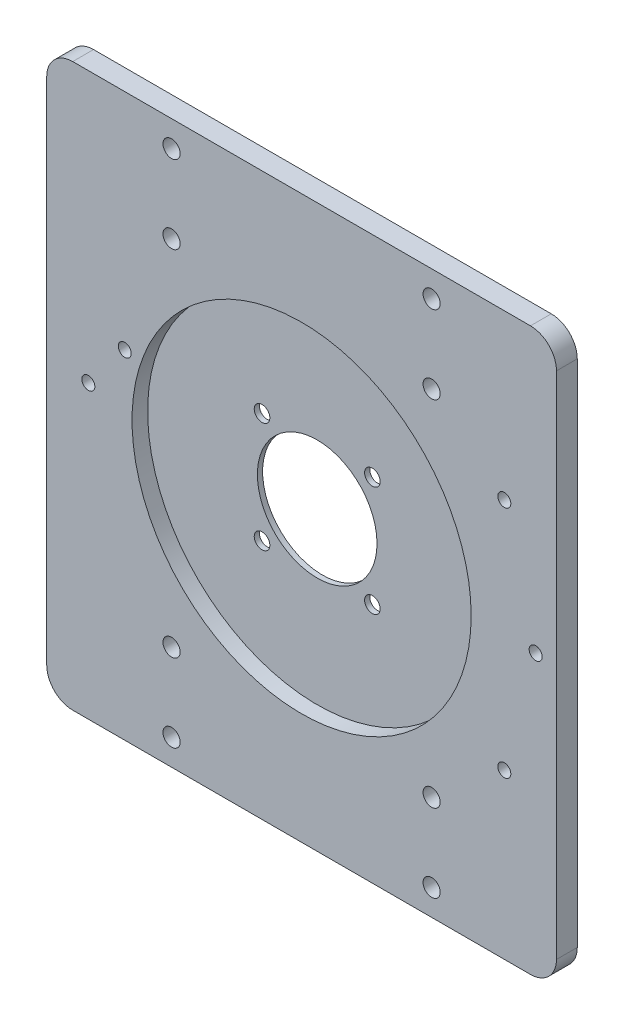
from build123d import *

# Parameters (mm, degrees)
SKETCH_1_W             = 98
SKETCH_1_H             = 108
EXTRUDE_1_DEPTH        = 4
SKETCH_2_R             = 11.5
CUT_EXTRUDE_1_DEPTH    = 10
SKETCH_3_R             = 32.6
CUT_EXTRUDE_2_DEPTH    = 3
SKETCH_4_R             = 1.5
CUT_EXTRUDE_3_DEPTH    = 2
FILLET_1_R             = 5
HOLE_WIZARD_M4_1_D     = 3.3
HOLE_WIZARD_M4_1_DEPTH = 10.1
HOLE_WIZARD_M4_1_TIP   = 0.991420021
HOLE_WIZARD_M3_1_D     = 2.5
HOLE_WIZARD_M3_1_DEPTH = 7.5
HOLE_WIZARD_M3_1_TIP   = 0.751075774
HOLE_WIZARD_M3_2_D     = 2.5
HOLE_WIZARD_M3_2_DEPTH = 7.5
HOLE_WIZARD_M3_2_TIP   = 0.751075774


with BuildPart() as part:
    # 草图1 → 凸台-拉伸1 (new body)
    with BuildSketch(Plane.XY):
        Rectangle(SKETCH_1_W, SKETCH_1_H)
    extrude(amount=EXTRUDE_1_DEPTH)

    # 草图2 → 切除-拉伸1 (cut)
    with BuildSketch(Plane.XY.offset(4)):
        Circle(SKETCH_2_R)
    extrude(amount=-CUT_EXTRUDE_1_DEPTH, mode=Mode.SUBTRACT)

    # 草图3 → 切除-拉伸2 (cut)
    with BuildSketch(Plane.XY.offset(4)):
        Circle(SKETCH_3_R)
    extrude(amount=-CUT_EXTRUDE_2_DEPTH, mode=Mode.SUBTRACT)

    # 草图4 → 切除-拉伸3 (cut)
    with BuildSketch(Plane.XY.offset(1)):
        with Locations((-10.606601718, 10.606601718)):
            Circle(SKETCH_4_R)
        with Locations((10.606601718, -10.606601718)):
            Circle(SKETCH_4_R)
        with Locations((10.606601718, 10.606601718)):
            Circle(SKETCH_4_R)
        with Locations((-10.606601718, -10.606601718)):
            Circle(SKETCH_4_R)
    extrude(amount=-CUT_EXTRUDE_3_DEPTH, mode=Mode.SUBTRACT)

    # 圆角1
    fillet_1_edges = [part.edges().sort_by_distance(p)[0] for p in [
        (-49, 54, 2),
        (49, 54, 2),
        (49, -54, 2),
        (-49, -54, 2),
    ]]
    fillet(fillet_1_edges, radius=FILLET_1_R)

    # M4 螺纹孔1
    with Locations(Plane(origin=(0, 0, 0), x_dir=(-1, 0, 0), z_dir=(0, 0, -1))):
        with Locations((-25, 49), (-25, 34), (25, 34), (25, 49), (-25, -34), (-25, -49), (25, -49), (25, -34)):
            Hole(HOLE_WIZARD_M4_1_D / 2, depth=HOLE_WIZARD_M4_1_DEPTH)
            with Locations((0, 0, -(HOLE_WIZARD_M4_1_DEPTH + HOLE_WIZARD_M4_1_TIP / 2))):  # 118° drill point
                Cone(0, HOLE_WIZARD_M4_1_D / 2, HOLE_WIZARD_M4_1_TIP, mode=Mode.SUBTRACT)

    # M3 螺纹孔1
    with Locations(Plane(origin=(0, 0, 0), x_dir=(-1, 0, 0), z_dir=(0, 0, -1))):
        with Locations((41, 2), (34, 11)):
            Hole(HOLE_WIZARD_M3_1_D / 2, depth=HOLE_WIZARD_M3_1_DEPTH)
            with Locations((0, 0, -(HOLE_WIZARD_M3_1_DEPTH + HOLE_WIZARD_M3_1_TIP / 2))):  # 118° drill point
                Cone(0, HOLE_WIZARD_M3_1_D / 2, HOLE_WIZARD_M3_1_TIP, mode=Mode.SUBTRACT)

    # M3 螺纹孔2
    with Locations(Plane.XY.offset(4)):
        with Locations((38.97114317, 22.5), (45, 0), (38.97114317, -22.5)):
            Hole(HOLE_WIZARD_M3_2_D / 2, depth=HOLE_WIZARD_M3_2_DEPTH)
            with Locations((0, 0, -(HOLE_WIZARD_M3_2_DEPTH + HOLE_WIZARD_M3_2_TIP / 2))):  # 118° drill point
                Cone(0, HOLE_WIZARD_M3_2_D / 2, HOLE_WIZARD_M3_2_TIP, mode=Mode.SUBTRACT)


solid = part.part
